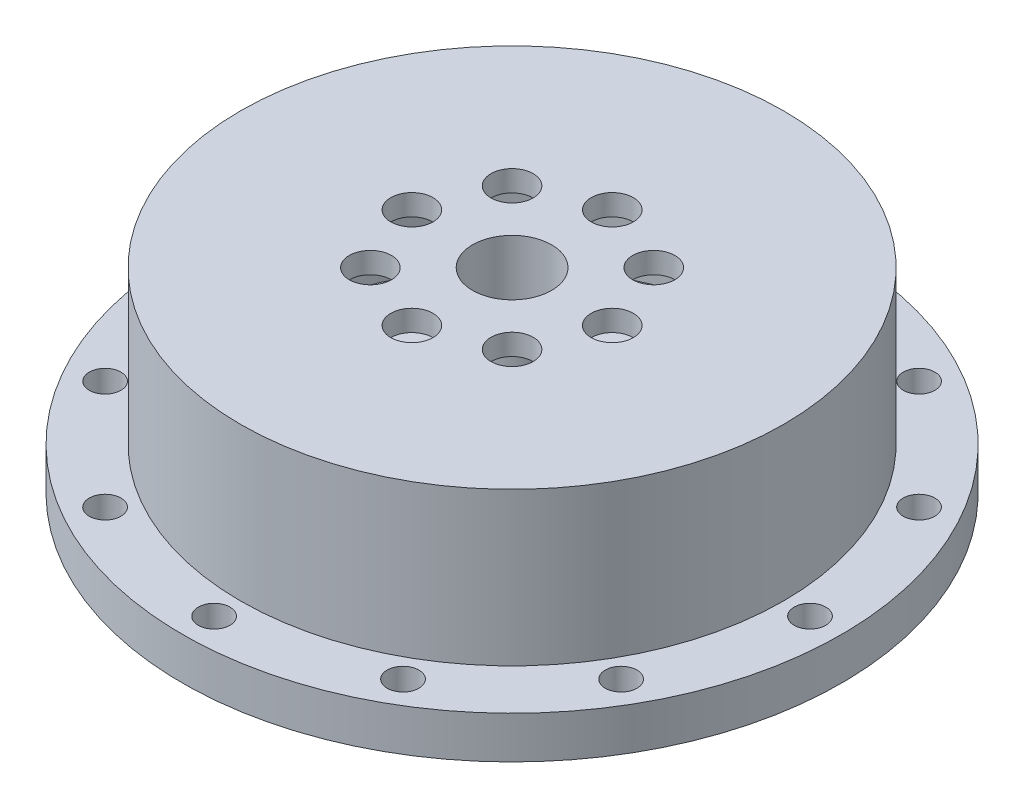
from build123d import *

# Parameters (mm, degrees)
SKETCH4_R           = 3
CUT_EXTRUDE1_DEPTH  = 10
SKETCH5_R           = 4
CUT_EXTRUDE2_DEPTH  = 10
SKETCH6_W           = 2
SKETCH6_H           = 3
BOSS_EXTRUDE1_DEPTH = 6


with BuildPart() as part:
    # Sketch1 → Revolve1 (revolve)
    with BuildSketch(Plane.XY):
        Polygon((10.5, 32.216109623), (10.5, 39.216109623), (48, 39.216109623), (48, 9.216109623), (7.5, 9.216109623), (7.5, 3.216109623), (10, 3.216109623), (10, 6.216109623), (36, 6.216109623), (36, 4.216109623), (39, 4.216109623), (39, 6.216109623), (62.5, 6.216109623), (62.5, 14.216109623), (51.5, 14.216109623), (51.5, 43.216109623), (7.5, 43.216109623), (7.5, 32.216109623), align=None)
    revolve(axis=Axis((0, 0, 0), (0, 1, 0)))

    # Sketch4 → Cut-Extrude1 (cut)
    with BuildSketch(Plane(origin=(0, 14.216109623, 0), x_dir=(1, 0, 0), z_dir=(0, 1, 0))):
        with Locations((56.5, 0)):
            Circle(SKETCH4_R)
        with Locations((48.930435314, -28.25)):
            Circle(SKETCH4_R)
        with Locations((28.25, -48.930435314)):
            Circle(SKETCH4_R)
        with Locations((0, -56.5)):
            Circle(SKETCH4_R)
        with Locations((-28.25, -48.930435314)):
            Circle(SKETCH4_R)
        with Locations((-48.930435314, -28.25)):
            Circle(SKETCH4_R)
        with Locations((-56.5, 0)):
            Circle(SKETCH4_R)
        with Locations((-48.930435314, 28.25)):
            Circle(SKETCH4_R)
        with Locations((-28.25, 48.930435314)):
            Circle(SKETCH4_R)
        with Locations((0, 56.5)):
            Circle(SKETCH4_R)
        with Locations((28.25, 48.930435314)):
            Circle(SKETCH4_R)
        with Locations((48.930435314, 28.25)):
            Circle(SKETCH4_R)
    extrude(amount=-CUT_EXTRUDE1_DEPTH, mode=Mode.SUBTRACT)

    # Sketch5 → Cut-Extrude2 (cut)
    with BuildSketch(Plane(origin=(0, 43.216109623, 0), x_dir=(1, 0, 0), z_dir=(0, 1, 0))):
        with Locations((19, 0)):
            Circle(SKETCH5_R)
        with Locations((13.435028843, -13.435028843)):
            Circle(SKETCH5_R)
        with Locations((0, -19)):
            Circle(SKETCH5_R)
        with Locations((-13.435028843, -13.435028843)):
            Circle(SKETCH5_R)
        with Locations((-19, 0)):
            Circle(SKETCH5_R)
        with Locations((-13.435028843, 13.435028843)):
            Circle(SKETCH5_R)
        with Locations((0, 19)):
            Circle(SKETCH5_R)
        with Locations((13.435028843, 13.435028843)):
            Circle(SKETCH5_R)
    extrude(amount=-CUT_EXTRUDE2_DEPTH, mode=Mode.SUBTRACT)

    # Sketch6 → Boss-Extrude1 (add)
    with BuildSketch(Plane.XZ.offset(-3.216109623)):
        with Locations((0, 7.5)):
            Rectangle(SKETCH6_W, SKETCH6_H)
    extrude(amount=-BOSS_EXTRUDE1_DEPTH)


solid = part.part
